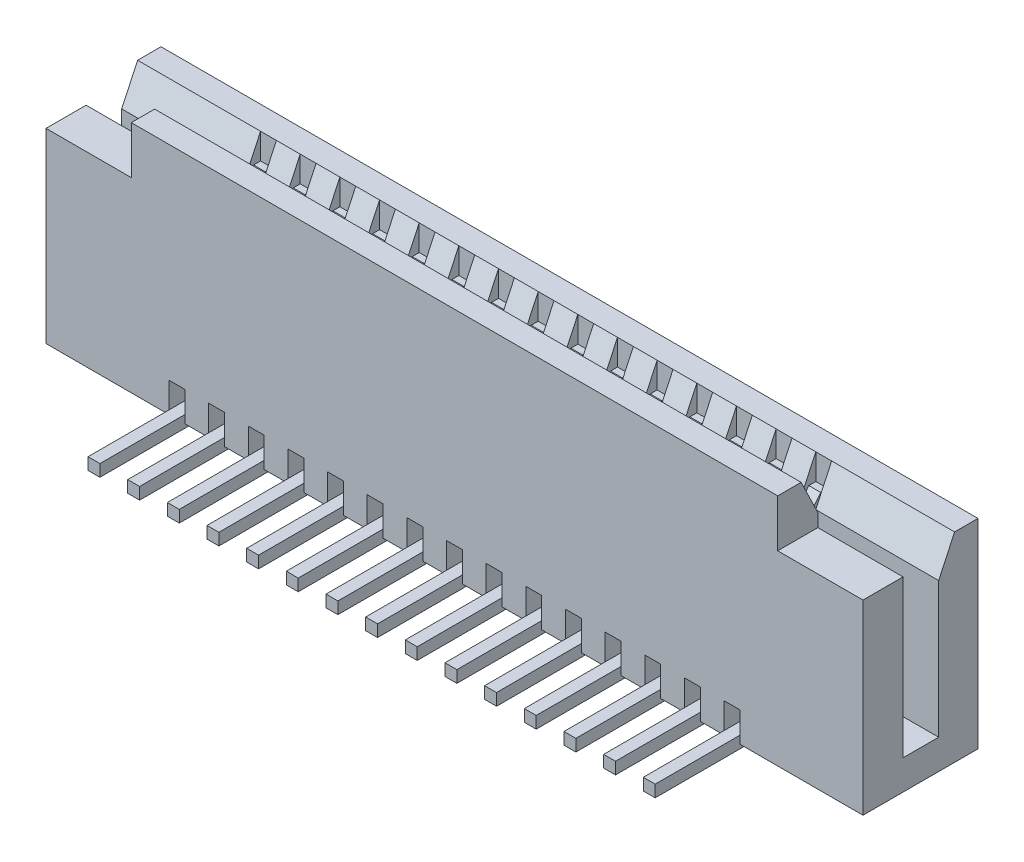
from build123d import *

# Parameters (mm, degrees)
SKETCH1_W                = 20.6
SKETCH1_H                = 2.9
BOSS_EXTRUDE1_DEPTH      = 5.9
CUT_EXTRUDE1_DEPTH       = 22.477255411
CUT_EXTRUDE2_DEPTH       = 22.477255411
CUT_EXTRUDE2_DEPTH_BACK  = 22.477255411
SKETCH5_W                = 20.6
SKETCH5_H                = 0.897511013
CUT_EXTRUDE3_DEPTH       = 3.421172811
SKETCH3_W                = 0.4
SKETCH3_H                = 6.863884208
CUT_EXTRUDE4_DEPTH       = 0.75
SKETCH6_W                = 0.4
SKETCH6_H                = 1.719871284
CUT_EXTRUDE5_DEPTH       = 12.958365273
SURFACE_EXTRUDE1_1_BACK  = 0.15
SURFACE_EXTRUDE1_1_DEPTH = 0.3
THICKEN1_T1              = 0.15
THICKEN1_T2              = 0.15
LPATTERN3_COUNT          = 15
LPATTERN3_PITCH          = 1
SURFACE_EXTRUDE2_2_BACK  = 0.15
SURFACE_EXTRUDE2_2_DEPTH = 0.3
THICKEN2_T1              = 0.15
THICKEN2_T2              = 0.15
LPATTERN4_COUNT          = 15
LPATTERN4_PITCH          = 1
SKETCH10_W               = 2.15
SKETCH10_H               = 1.2
CUT_EXTRUDE6_DEPTH       = 1.2


with BuildPart() as part:
    # Sketch1 → Boss-Extrude1 (new body)
    with BuildSketch(Plane(origin=(0, 0, 0), x_dir=(1, 0, 0), z_dir=(0, 1, 0))):
        Rectangle(SKETCH1_W, SKETCH1_H)
    extrude(amount=BOSS_EXTRUDE1_DEPTH)

    # Sketch2 → Cut-Extrude1 (cut, through all)
    with BuildSketch(Plane(origin=(10.3, 0, 0), x_dir=(0, 0, -1), z_dir=(1, 0, 0))):
        Polygon((-0.859871284, 5.9), (-0.438998362, 5.032165209), (1.45, 5.032165209), (1.45, 5.9), align=None)
    extrude(amount=-CUT_EXTRUDE1_DEPTH, mode=Mode.SUBTRACT)

    # Sketch4 → Cut-Extrude2 (cut, two sides)
    with BuildSketch(Plane.ZY.offset(10.3)) as cut_extrude2_sk:
        Polygon((-9.766289128, 24.13176388), (-0.86, 5.032165209), (-0.458512651, 4.171172811), (0.438998362, 4.171172811), (0.438998362, 5.032165209), (0.438998362, 26.106240644), (-7.567180708, 67.487005723), (-17.772468198, 65.512528959), align=None)
    extrude(amount=CUT_EXTRUDE2_DEPTH, mode=Mode.SUBTRACT)
    extrude(cut_extrude2_sk.sketch, amount=-CUT_EXTRUDE2_DEPTH_BACK, mode=Mode.SUBTRACT)

    # Sketch5 → Cut-Extrude3 (cut)
    with BuildSketch(Plane(origin=(0, 4.171172811, 0), x_dir=(1, 0, 0), z_dir=(0, 1, 0))):
        with Locations((0, 0.009757145)):
            Rectangle(SKETCH5_W, SKETCH5_H)
    extrude(amount=-CUT_EXTRUDE3_DEPTH, mode=Mode.SUBTRACT)

    # Sketch3 → Cut-Extrude4 (cut)
    with BuildSketch(Plane.XZ):
        with Locations((-7, -0.729625487)):
            Rectangle(SKETCH3_W, SKETCH3_H)
        with Locations((-6, -0.729625487)):
            Rectangle(SKETCH3_W, SKETCH3_H)
        with Locations((-5, -0.729625487)):
            Rectangle(SKETCH3_W, SKETCH3_H)
        with Locations((-4, -0.729625487)):
            Rectangle(SKETCH3_W, SKETCH3_H)
        with Locations((-3, -0.729625487)):
            Rectangle(SKETCH3_W, SKETCH3_H)
        with Locations((-2, -0.729625487)):
            Rectangle(SKETCH3_W, SKETCH3_H)
        with Locations((-1, -0.729625487)):
            Rectangle(SKETCH3_W, SKETCH3_H)
        with Locations((0, -0.729625487)):
            Rectangle(SKETCH3_W, SKETCH3_H)
        with Locations((1, -0.729625487)):
            Rectangle(SKETCH3_W, SKETCH3_H)
        with Locations((2, -0.729625487)):
            Rectangle(SKETCH3_W, SKETCH3_H)
        with Locations((3, -0.729625487)):
            Rectangle(SKETCH3_W, SKETCH3_H)
        with Locations((4, -0.729625487)):
            Rectangle(SKETCH3_W, SKETCH3_H)
        with Locations((5, -0.729625487)):
            Rectangle(SKETCH3_W, SKETCH3_H)
        with Locations((6, -0.729625487)):
            Rectangle(SKETCH3_W, SKETCH3_H)
        with Locations((7, -0.729625487)):
            Rectangle(SKETCH3_W, SKETCH3_H)
    extrude(amount=-CUT_EXTRUDE4_DEPTH, mode=Mode.SUBTRACT)

    # Sketch6 → Cut-Extrude5 (cut, through all)
    with BuildSketch(Plane(origin=(0, 5.9, 0), x_dir=(1, 0, 0), z_dir=(0, 1, 0))):
        with Locations((-7, 6.4358e-05)):
            Rectangle(SKETCH6_W, SKETCH6_H)
        with Locations((-6, 6.4358e-05)):
            Rectangle(SKETCH6_W, SKETCH6_H)
        with Locations((-5, 6.4358e-05)):
            Rectangle(SKETCH6_W, SKETCH6_H)
        with Locations((-4, 6.4358e-05)):
            Rectangle(SKETCH6_W, SKETCH6_H)
        with Locations((-3, 6.4358e-05)):
            Rectangle(SKETCH6_W, SKETCH6_H)
        with Locations((-2, 6.4358e-05)):
            Rectangle(SKETCH6_W, SKETCH6_H)
        with Locations((-1, 6.4358e-05)):
            Rectangle(SKETCH6_W, SKETCH6_H)
        with Locations((0, 6.4358e-05)):
            Rectangle(SKETCH6_W, SKETCH6_H)
        with Locations((1, 6.4358e-05)):
            Rectangle(SKETCH6_W, SKETCH6_H)
        with Locations((2, 6.4358e-05)):
            Rectangle(SKETCH6_W, SKETCH6_H)
        with Locations((3, 6.4358e-05)):
            Rectangle(SKETCH6_W, SKETCH6_H)
        with Locations((4, 6.4358e-05)):
            Rectangle(SKETCH6_W, SKETCH6_H)
        with Locations((5, 6.4358e-05)):
            Rectangle(SKETCH6_W, SKETCH6_H)
        with Locations((6, 6.4358e-05)):
            Rectangle(SKETCH6_W, SKETCH6_H)
        with Locations((7, 6.4358e-05)):
            Rectangle(SKETCH6_W, SKETCH6_H)
    extrude(amount=-CUT_EXTRUDE5_DEPTH, mode=Mode.SUBTRACT)

    # Sketch10 → Cut-Extrude6 (cut)
    with BuildSketch(Plane.XY.offset(1.45)):
        with Locations((-9.225, 5.3)):
            Rectangle(SKETCH10_W, SKETCH10_H)
        with Locations((9.225, 5.3)):
            Rectangle(SKETCH10_W, SKETCH10_H)
    extrude(amount=-CUT_EXTRUDE6_DEPTH, mode=Mode.SUBTRACT)


with BuildPart() as body_2:
    # Surface-Extrude1: a surface, the sketch's curves swept straight by 0.3 mm
    with BuildLine(Plane(origin=(7, 0, 0), x_dir=(0, 0, -1), z_dir=(1, 0, 0)).offset(-SURFACE_EXTRUDE1_1_BACK), mode=Mode.PRIVATE) as surface_extrude1_1_path:
        Line((2.324335617, 0), (0.618512651, 0))
        Line((0.618512651, 0), (0.618512651, 4.171172811))
        Line((0.618512651, 4.171172811), (0.706676367, 4.282932038))
        Line((0.706676367, 4.282932038), (0.810305597, 4.282932038))
    surface_extrude1_1 = Shell.extrude(surface_extrude1_1_path.wire(), (1 * SURFACE_EXTRUDE1_1_DEPTH, 0 * SURFACE_EXTRUDE1_1_DEPTH, 0 * SURFACE_EXTRUDE1_1_DEPTH))
    add(Solid.thicken(surface_extrude1_1, THICKEN1_T1))
    add(Solid.thicken(surface_extrude1_1, -THICKEN1_T2))


with BuildPart() as lpattern3_1:
    # LPattern3: pattern copy
    add(body_2.part.moved(Location(Vector(-1, 0, 0) * (1 * LPATTERN3_PITCH))))


with BuildPart() as lpattern3_2:
    # LPattern3: pattern copy
    add(body_2.part.moved(Location(Vector(-1, 0, 0) * (2 * LPATTERN3_PITCH))))


with BuildPart() as lpattern3_3:
    # LPattern3: pattern copy
    add(body_2.part.moved(Location(Vector(-1, 0, 0) * (3 * LPATTERN3_PITCH))))


with BuildPart() as lpattern3_4:
    # LPattern3: pattern copy
    add(body_2.part.moved(Location(Vector(-1, 0, 0) * (4 * LPATTERN3_PITCH))))


with BuildPart() as lpattern3_5:
    # LPattern3: pattern copy
    add(body_2.part.moved(Location(Vector(-1, 0, 0) * (5 * LPATTERN3_PITCH))))


with BuildPart() as lpattern3_6:
    # LPattern3: pattern copy
    add(body_2.part.moved(Location(Vector(-1, 0, 0) * (6 * LPATTERN3_PITCH))))


with BuildPart() as lpattern3_7:
    # LPattern3: pattern copy
    add(body_2.part.moved(Location(Vector(-1, 0, 0) * (7 * LPATTERN3_PITCH))))


with BuildPart() as lpattern3_8:
    # LPattern3: pattern copy
    add(body_2.part.moved(Location(Vector(-1, 0, 0) * (8 * LPATTERN3_PITCH))))


with BuildPart() as lpattern3_9:
    # LPattern3: pattern copy
    add(body_2.part.moved(Location(Vector(-1, 0, 0) * (9 * LPATTERN3_PITCH))))


with BuildPart() as lpattern3_10:
    # LPattern3: pattern copy
    add(body_2.part.moved(Location(Vector(-1, 0, 0) * (10 * LPATTERN3_PITCH))))


with BuildPart() as lpattern3_11:
    # LPattern3: pattern copy
    add(body_2.part.moved(Location(Vector(-1, 0, 0) * (11 * LPATTERN3_PITCH))))


with BuildPart() as lpattern3_12:
    # LPattern3: pattern copy
    add(body_2.part.moved(Location(Vector(-1, 0, 0) * (12 * LPATTERN3_PITCH))))


with BuildPart() as lpattern3_13:
    # LPattern3: pattern copy
    add(body_2.part.moved(Location(Vector(-1, 0, 0) * (13 * LPATTERN3_PITCH))))


with BuildPart() as lpattern3_14:
    # LPattern3: pattern copy
    add(body_2.part.moved(Location(Vector(-1, 0, 0) * (14 * LPATTERN3_PITCH))))


with BuildPart() as body_17:
    # Surface-Extrude2: a surface, the sketch's curves swept straight by 0.3 mm
    with BuildLine(Plane(origin=(7, 0, 0), x_dir=(0, 0, -1), z_dir=(1, 0, 0)).offset(-SURFACE_EXTRUDE2_2_BACK), mode=Mode.PRIVATE) as surface_extrude2_2_path:
        Line((-3.540018861, 0), (-0.517559694, 0))
        Line((-0.517559694, 0), (-0.517559694, 4.36783966))
        Line((-0.517559694, 4.36783966), (-0.17495155, 4.785654471))
        Line((-0.17495155, 4.785654471), (-0.275227104, 5.032165209))
        Line((-0.275227104, 5.032165209), (-0.718249464, 5.032165209))
    surface_extrude2_2 = Shell.extrude(surface_extrude2_2_path.wire(), (1 * SURFACE_EXTRUDE2_2_DEPTH, 0 * SURFACE_EXTRUDE2_2_DEPTH, 0 * SURFACE_EXTRUDE2_2_DEPTH))
    add(Solid.thicken(surface_extrude2_2, THICKEN2_T1))
    add(Solid.thicken(surface_extrude2_2, -THICKEN2_T2))


with BuildPart() as lpattern4_1:
    # LPattern4: pattern copy
    add(body_17.part.moved(Location(Vector(-1, 0, 0) * (1 * LPATTERN4_PITCH))))


with BuildPart() as lpattern4_2:
    # LPattern4: pattern copy
    add(body_17.part.moved(Location(Vector(-1, 0, 0) * (2 * LPATTERN4_PITCH))))


with BuildPart() as lpattern4_3:
    # LPattern4: pattern copy
    add(body_17.part.moved(Location(Vector(-1, 0, 0) * (3 * LPATTERN4_PITCH))))


with BuildPart() as lpattern4_4:
    # LPattern4: pattern copy
    add(body_17.part.moved(Location(Vector(-1, 0, 0) * (4 * LPATTERN4_PITCH))))


with BuildPart() as lpattern4_5:
    # LPattern4: pattern copy
    add(body_17.part.moved(Location(Vector(-1, 0, 0) * (5 * LPATTERN4_PITCH))))


with BuildPart() as lpattern4_6:
    # LPattern4: pattern copy
    add(body_17.part.moved(Location(Vector(-1, 0, 0) * (6 * LPATTERN4_PITCH))))


with BuildPart() as lpattern4_7:
    # LPattern4: pattern copy
    add(body_17.part.moved(Location(Vector(-1, 0, 0) * (7 * LPATTERN4_PITCH))))


with BuildPart() as lpattern4_8:
    # LPattern4: pattern copy
    add(body_17.part.moved(Location(Vector(-1, 0, 0) * (8 * LPATTERN4_PITCH))))


with BuildPart() as lpattern4_9:
    # LPattern4: pattern copy
    add(body_17.part.moved(Location(Vector(-1, 0, 0) * (9 * LPATTERN4_PITCH))))


with BuildPart() as lpattern4_10:
    # LPattern4: pattern copy
    add(body_17.part.moved(Location(Vector(-1, 0, 0) * (10 * LPATTERN4_PITCH))))


with BuildPart() as lpattern4_11:
    # LPattern4: pattern copy
    add(body_17.part.moved(Location(Vector(-1, 0, 0) * (11 * LPATTERN4_PITCH))))


with BuildPart() as lpattern4_12:
    # LPattern4: pattern copy
    add(body_17.part.moved(Location(Vector(-1, 0, 0) * (12 * LPATTERN4_PITCH))))


with BuildPart() as lpattern4_13:
    # LPattern4: pattern copy
    add(body_17.part.moved(Location(Vector(-1, 0, 0) * (13 * LPATTERN4_PITCH))))


with BuildPart() as lpattern4_14:
    # LPattern4: pattern copy
    add(body_17.part.moved(Location(Vector(-1, 0, 0) * (14 * LPATTERN4_PITCH))))


solid = Compound([part.part, body_2.part, lpattern3_1.part, lpattern3_2.part, lpattern3_3.part, lpattern3_4.part, lpattern3_5.part, lpattern3_6.part, lpattern3_7.part, lpattern3_8.part, lpattern3_9.part, lpattern3_10.part, lpattern3_11.part, lpattern3_12.part, lpattern3_13.part, lpattern3_14.part, body_17.part, lpattern4_1.part, lpattern4_2.part, lpattern4_3.part, lpattern4_4.part, lpattern4_5.part, lpattern4_6.part, lpattern4_7.part, lpattern4_8.part, lpattern4_9.part, lpattern4_10.part, lpattern4_11.part, lpattern4_12.part, lpattern4_13.part, lpattern4_14.part])
